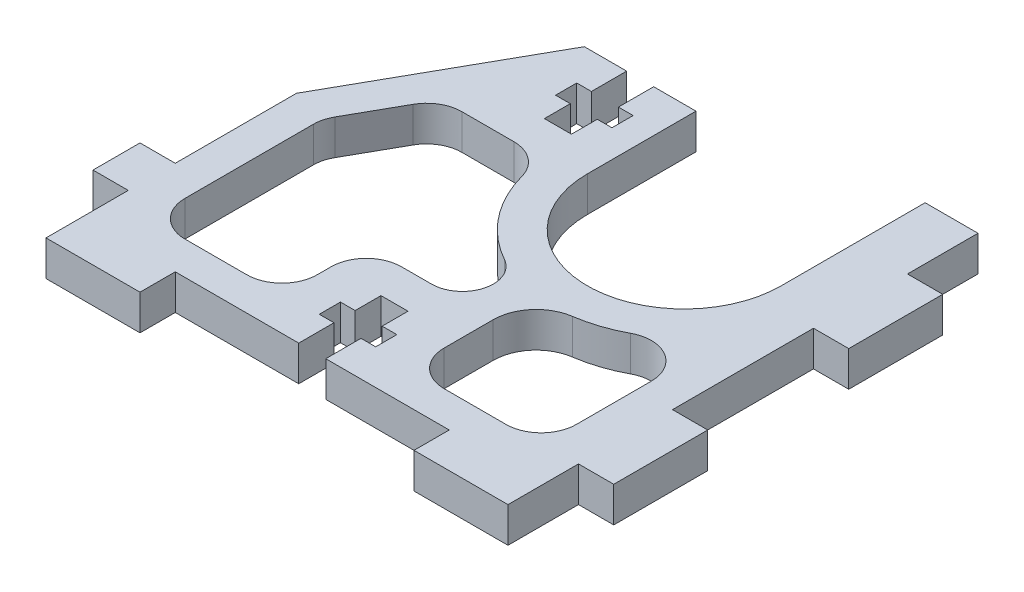
from build123d import *

# Parameters (mm, degrees)
SKETCH1_W           = 30.5
SKETCH1_H           = 34
BOSS_EXTRUDE1_DEPTH = 1.5
BOSS_EXTRUDE2_DEPTH = 3
SKETCH3_W           = 3
SKETCH3_H           = 8
SKETCH3_W_2         = 8
SKETCH3_H_2         = 3
BOSS_EXTRUDE3_DEPTH = 3
CUT_EXTRUDE1_DEPTH  = 4.0000001
CUT_EXTRUDE2_DEPTH  = 4.0000001
SKETCH6_W           = 8
SKETCH6_H           = 3
CUT_EXTRUDE3_DEPTH  = 4.0000001
CUT_EXTRUDE4_DEPTH  = 4.0000001
CUT_EXTRUDE6_DEPTH  = 4.0000001
SKETCH9_W           = 3
SKETCH9_H           = 4
BOSS_EXTRUDE4_DEPTH = 3
CUT_EXTRUDE7_DEPTH  = 4
FILLET1_R           = 3
BOSS_EXTRUDE5_DEPTH = 3


with BuildPart() as part:
    # Sketch1 → Boss-Extrude1 (new body, symmetric)
    with BuildSketch(Plane(origin=(0, 0, 0), x_dir=(1, 0, 0), z_dir=(0, 1, 0))):
        Rectangle(SKETCH1_W, SKETCH1_H)
    extrude(amount=BOSS_EXTRUDE1_DEPTH, both=True)

    # Sketch2 → Boss-Extrude2 (add)
    with BuildSketch(Plane(origin=(0, 1.5, 0), x_dir=(1, 0, 0), z_dir=(0, 1, 0))):
        with BuildLine():
            Line((-15.25, 17), (-24.07, 1.308996208))
            add(Edge.make_bspline(
                [(-24.07, 1.308996208), (-25.612124036, -1.43448158), (-30.226003395, -1.5229993), (-46.69780929, -11.088418218), (-55.382760657, -10.307171359), (-55.382760657, -17)],
                knots=[0, 0, 0, 0, 0.221130071, 0.603599568, 1, 1, 1, 1], degree=3))
            Line((-55.382760657, -17), (-15.25, -17))
            Line((-15.25, -17), (-15.25, 17))
        make_face()
    extrude(amount=-BOSS_EXTRUDE2_DEPTH)

    # Sketch3 → Boss-Extrude3 (add)
    with BuildSketch(Plane(origin=(0, 1.5, 0), x_dir=(1, 0, 0), z_dir=(0, 1, 0))):
        with Locations((16.75, 10)):
            Rectangle(SKETCH3_W, SKETCH3_H)
        with Locations((16.75, -10)):
            Rectangle(SKETCH3_W, SKETCH3_H)
        with Locations((-11.25, 18.5)):
            Rectangle(SKETCH3_W_2, SKETCH3_H_2)
        with Locations((11.25, 18.5)):
            Rectangle(SKETCH3_W_2, SKETCH3_H_2)
        with Locations((-51.382760657, -18.5)):
            Rectangle(SKETCH3_W_2, SKETCH3_H_2)
        with Locations((11.25, -18.5)):
            Rectangle(SKETCH3_W_2, SKETCH3_H_2)
        with Locations((-20.066380328, -18.5)):
            Rectangle(SKETCH3_W_2, SKETCH3_H_2)
    extrude(amount=-BOSS_EXTRUDE3_DEPTH)

    # Sketch4 → Cut-Extrude1 (cut, through all)
    with BuildSketch(Plane(origin=(0, 1.5, 0), x_dir=(1, 0, 0), z_dir=(0, 1, 0))):
        Polygon((-2.008190164, -14), (-2.008190164, -12.2), (-3.258190164, -12.2), (-3.258190164, -10), (-5.558190164, -10), (-5.558190164, -12.2), (-6.808190164, -12.2), (-6.808190164, -14), (-5.558190164, -14), (-5.558190164, -17), (-3.258190164, -17), (-3.258190164, -14), align=None)
        Polygon((-33.324570493, -14), (-33.324570493, -12.2), (-34.574570493, -12.2), (-34.574570493, -10), (-36.874570493, -10), (-36.874570493, -12.2), (-38.124570493, -12.2), (-38.124570493, -14), (-36.874570493, -14), (-36.874570493, -17), (-34.574570493, -17), (-34.574570493, -14), align=None)
    extrude(amount=-CUT_EXTRUDE1_DEPTH, mode=Mode.SUBTRACT)

    # Sketch5 → Cut-Extrude2 (cut, through all)
    with BuildSketch(Plane(origin=(0, 1.5, 0), x_dir=(1, 0, 0), z_dir=(0, 1, 0))):
        with BuildLine():
            Line((10.75, 20), (10.75, 7.75))
            ThreePointArc((10.75, 7.75), (2.5, -0.5), (-5.75, 7.75))
            Line((-5.75, 7.75), (-5.75, 20))
            Line((-5.75, 20), (10.75, 20))
        make_face()
    extrude(amount=-CUT_EXTRUDE2_DEPTH, mode=Mode.SUBTRACT)

    # Sketch6 → Cut-Extrude3 (cut, through all)
    with BuildSketch(Plane(origin=(0, 1.5, 0), x_dir=(1, 0, 0), z_dir=(0, 1, 0))):
        with Locations((-11.25, 18.5)):
            Rectangle(SKETCH6_W, SKETCH6_H)
    extrude(amount=-CUT_EXTRUDE3_DEPTH, mode=Mode.SUBTRACT)

    # Sketch7 → Cut-Extrude4 (cut, through all)
    with BuildSketch(Plane(origin=(0, 1.5, 0), x_dir=(1, 0, 0), z_dir=(0, 1, 0))):
        Polygon((-11.65, 17), (-9.35, 17), (-9.35, 14), (-8.1, 14), (-8.1, 12.2), (-9.35, 12.2), (-9.35, 10), (-11.65, 10), (-11.65, 12.2), (-12.9, 12.2), (-12.9, 14), (-11.65, 14), align=None)
    extrude(amount=-CUT_EXTRUDE4_DEPTH, mode=Mode.SUBTRACT)

    # Sketch8 → Cut-Extrude6 (cut, through all)
    with BuildSketch(Plane(origin=(0, 1.5, 0), x_dir=(1, 0, 0), z_dir=(0, 1, 0))):
        with BuildLine():
            Line((-24.066380328, -17), (-24.066380328, 1.315435696))
            Line((-24.066380328, 1.315435696), (-24.07, 1.308996208))
            add(Edge.make_bspline(
                [(-24.07, 1.308996208), (-25.612124036, -1.43448158), (-30.226003395, -1.5229993), (-46.69780929, -11.088418218), (-55.382760657, -10.307171359), (-55.382760657, -17)],
                knots=[0, 0, 0, 0, 0.221130071, 0.603599568, 1, 1, 1, 1], degree=3))
            Line((-55.382760657, -17), (-55.382760657, -20))
            Line((-55.382760657, -20), (-47.382760657, -20))
            Line((-47.382760657, -20), (-47.382760657, -17))
            Line((-47.382760657, -17), (-36.874570493, -17))
            Line((-36.874570493, -17), (-36.874570493, -14))
            Line((-36.874570493, -14), (-38.124570493, -14))
            Line((-38.124570493, -14), (-38.124570493, -12.2))
            Line((-38.124570493, -12.2), (-36.874570493, -12.2))
            Line((-36.874570493, -12.2), (-36.874570493, -10))
            Line((-36.874570493, -10), (-34.574570493, -10))
            Line((-34.574570493, -10), (-34.574570493, -12.2))
            Line((-34.574570493, -12.2), (-33.324570493, -12.2))
            Line((-33.324570493, -12.2), (-33.324570493, -14))
            Line((-33.324570493, -14), (-34.574570493, -14))
            Line((-34.574570493, -14), (-34.574570493, -17))
            Line((-34.574570493, -17), (-24.066380328, -17))
        make_face()
    extrude(amount=-CUT_EXTRUDE6_DEPTH, mode=Mode.SUBTRACT)

    # Sketch9 → Boss-Extrude4 (add)
    with BuildSketch(Plane(origin=(0, 1.5, 0), x_dir=(1, 0, 0), z_dir=(0, 1, 0))):
        with Locations((-25.566380328, -11)):
            Rectangle(SKETCH9_W, SKETCH9_H)
    extrude(amount=-BOSS_EXTRUDE4_DEPTH)

    # Sketch10 → Cut-Extrude7 (cut, through all)
    with BuildSketch(Plane(origin=(0, 1.5, 0), x_dir=(1, 0, 0), z_dir=(0, 1, 0))):
        with BuildLine():
            Line((-21.066380328, 0.530062836), (-21.066380328, -14.173024042))
            Line((-21.066380328, -14.173024042), (-9.808190164, -14.173024042))
            Line((-9.808190164, -14.173024042), (-9.808190164, -7))
            Line((-9.808190164, -7), (0.991809836, -7))
            Line((0.991809836, -7), (0.991809836, -14.173024042))
            Line((0.991809836, -14.173024042), (12.25, -14.173024042))
            Line((12.25, -14.173024042), (12.25, 2.13751392))
            ThreePointArc((12.25, 2.13751392), (-0.04063544, -3.20936456), (-8.72497216, 7))
            Line((-8.72497216, 7), (-17.429592871, 7))
            Line((-17.429592871, 7), (-21.066380328, 0.530062836))
        make_face()
    extrude(amount=-CUT_EXTRUDE7_DEPTH, mode=Mode.SUBTRACT)

    # Fillet1
    fillet1_edges = [part.edges().sort_by_distance(p)[0] for p in [
        (-21.066380328, 0, -0.530062836),
        (-17.429592871, 0, -7),
        (-8.72497216, 0, -7),
        (12.25, 0, -2.13751392),
        (12.25, 0, 14.173024042),
        (0.991809836, 0, 14.173024042),
        (-9.808190164, 0, 7),
        (-9.808190164, 0, 14.173024042),
        (-21.066380328, 0, 14.173024042),
    ]]
    fillet(fillet1_edges, radius=FILLET1_R)

    # Sketch11 → Boss-Extrude5 (add)
    with BuildSketch(Plane(origin=(0, 1.5, 0), x_dir=(1, 0, 0), z_dir=(0, 1, 0))):
        with BuildLine():
            Line((-4.256338517, -7), (0.991809836, -7))
            ThreePointArc((0.991809836, -7), (1.882552513, -4.608606487), (4.120680317, -3.382649968))
            ThreePointArc((4.120680317, -3.382649968), (0.464289311, -3.31428407), (-2.97698799, -2.076754426))
            ThreePointArc((-2.97698799, -2.076754426), (-1.712960608, -5.03307181), (-4.256338517, -7))
        make_face()
    extrude(amount=-BOSS_EXTRUDE5_DEPTH)


solid = part.part
